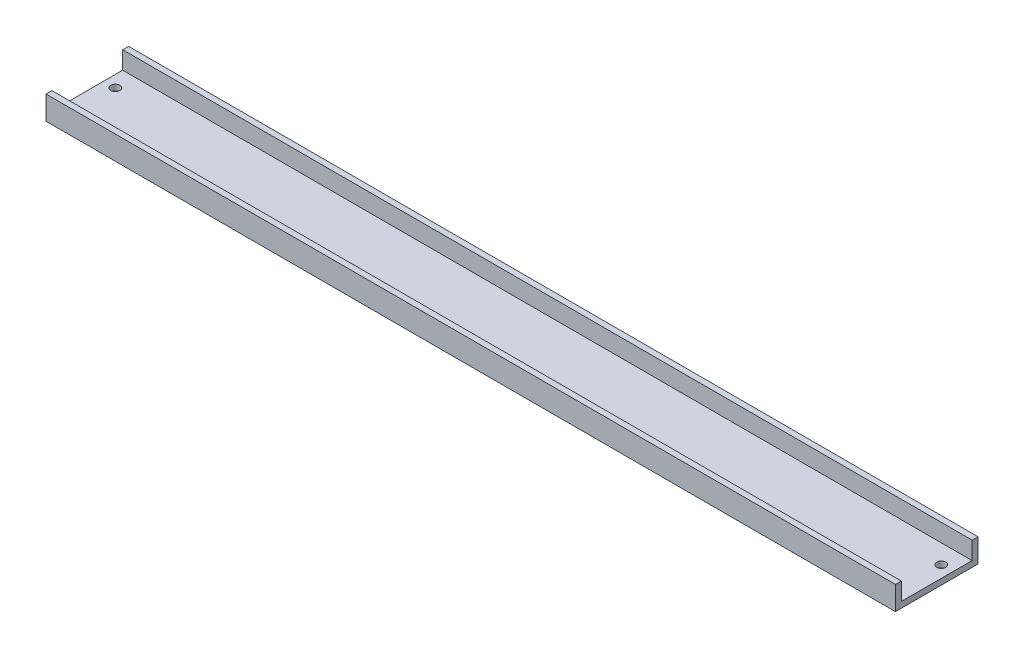
from build123d import *

# Parameters (mm, degrees)
SKETCH1_W                    = 44.45
SKETCH1_H                    = 12.7
BOSS_EXTRUDE1_DEPTH          = 457.2
SKETCH2_W                    = 38.1
SKETCH2_H                    = 9.525
CUT_EXTRUDE1_DEPTH           = 457.2
F_10_0_1935_DIAMETER_HOLE3_D = 4.9149


with BuildPart() as part:
    # Sketch1 → Boss-Extrude1 (new body)
    with BuildSketch(Plane(origin=(0, 0, 0), x_dir=(0, 0, -1), z_dir=(1, 0, 0))):
        with Locations((22.225, 6.35)):
            Rectangle(SKETCH1_W, SKETCH1_H)
    extrude(amount=BOSS_EXTRUDE1_DEPTH)

    # Sketch2 → Cut-Extrude1 (cut)
    with BuildSketch(Plane.ZY):
        with Locations((-22.225, 7.9375)):
            Rectangle(SKETCH2_W, SKETCH2_H)
    extrude(amount=-CUT_EXTRUDE1_DEPTH, mode=Mode.SUBTRACT)

    # #10 (0.1935) Diameter Hole3 (through all)
    with Locations(Plane(origin=(450.832652449, 0, -31.016622241), x_dir=(0, 0, -1), z_dir=(0, -1, 0))):
        with Locations((0, 0), (-25.407873942, -0.017970114), (0.032060561, -444.542685672), (-25.413373891, -444.602634996)):
            Hole(F_10_0_1935_DIAMETER_HOLE3_D / 2)


solid = part.part
